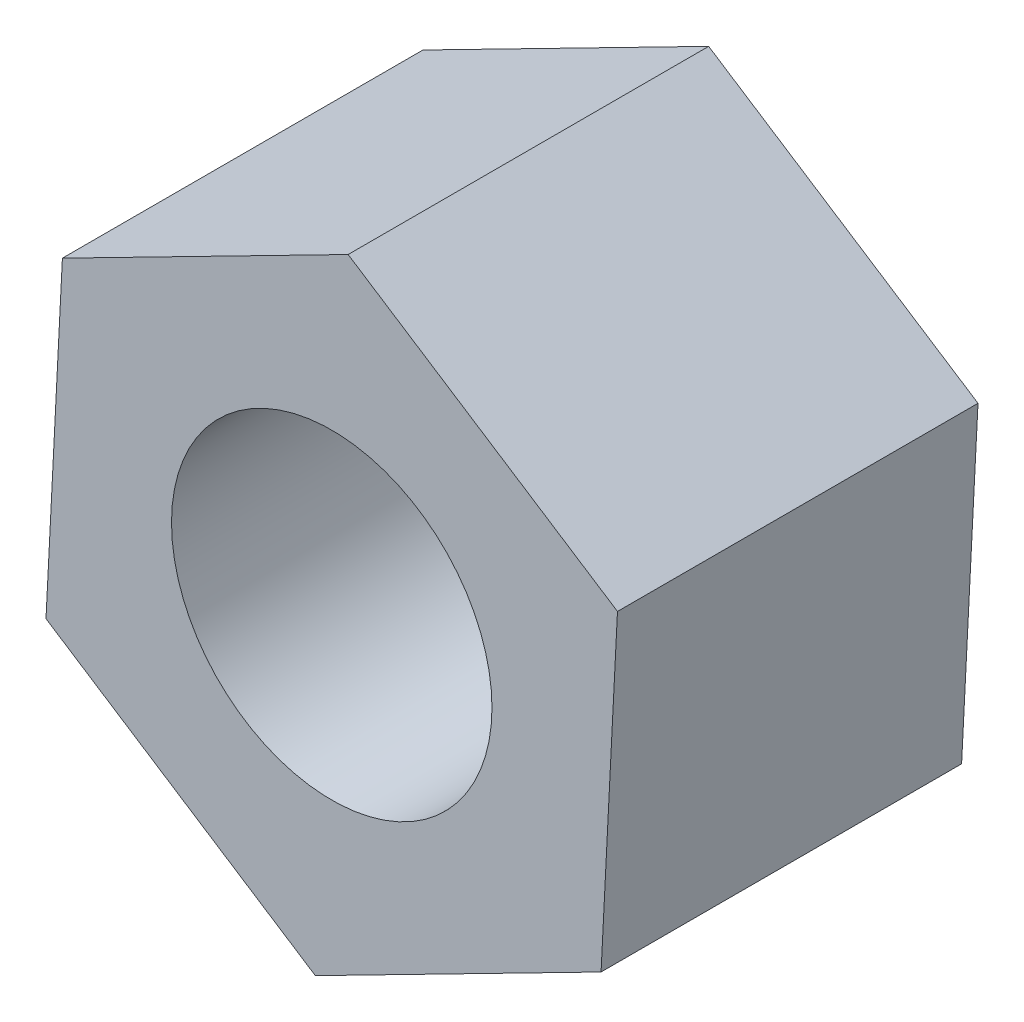
from build123d import *

# Parameters (mm, degrees)
BOSS_EXTRUDE1_DEPTH = 4.5
SKETCH2_R           = 4
CUT_EXTRUDE1_DEPTH  = 9


with BuildPart() as part:
    # Sketch1 → Boss-Extrude1 (new body, symmetric)
    with BuildSketch(Plane.XY):
        Polygon((6.723407542, -4.354716537), (7.132998919, 3.645283463), (0.409591377, 8), (-6.723407542, 4.354716537), (-7.132998919, -3.645283463), (-0.409591377, -8), align=None)
    extrude(amount=BOSS_EXTRUDE1_DEPTH, both=True)

    # Sketch2 → Cut-Extrude1 (cut)
    with BuildSketch(Plane(origin=(0, 0, -4.5), x_dir=(-1, 0, 0), z_dir=(0, 0, -1))):
        Circle(SKETCH2_R)
    extrude(amount=-CUT_EXTRUDE1_DEPTH, mode=Mode.SUBTRACT)


solid = part.part
